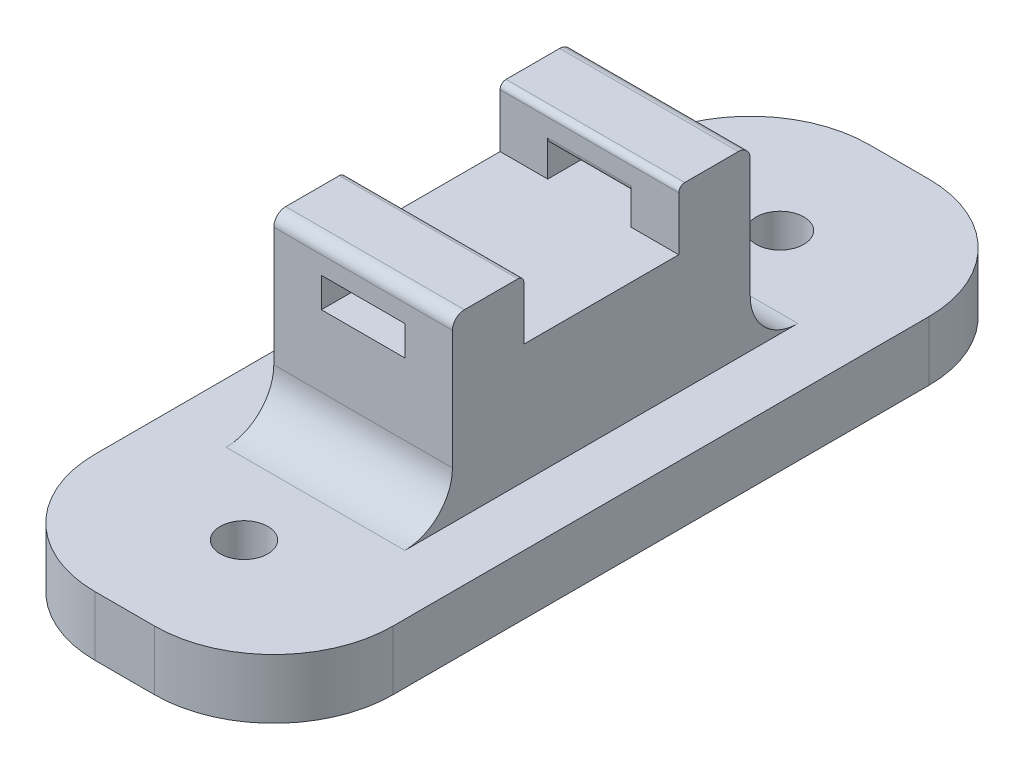
from build123d import *

# Parameters (mm, degrees)
SKETCH1_W           = 25
SKETCH1_H           = 65
BOSS_EXTRUDE1_DEPTH = 5
SKETCH2_R           = 2
CUT_EXTRUDE1_DEPTH  = 6
SKETCH3_W           = 15
SKETCH3_H           = 25
BOSS_EXTRUDE2_DEPTH = 10
SKETCH4_W           = 15
SKETCH4_H           = 6
BOSS_EXTRUDE3_DEPTH = 5
SKETCH5_W           = 7
SKETCH5_H           = 2.5
CUT_EXTRUDE2_DEPTH  = 46
FILLET1_R           = 0.5
FILLET2_R           = 0.5
FILLET3_R           = 1
FILLET4_R           = 10
FILLET5_R           = 4


with BuildPart() as part:
    # Sketch1 → Boss-Extrude1 (new body)
    with BuildSketch(Plane(origin=(0, 0, 0), x_dir=(1, 0, 0), z_dir=(0, 1, 0))):
        with Locations((12.5, 32.5)):
            Rectangle(SKETCH1_W, SKETCH1_H)
    extrude(amount=BOSS_EXTRUDE1_DEPTH)

    # Sketch2 → Cut-Extrude1 (cut, through all)
    with BuildSketch(Plane(origin=(0, 0, 0), x_dir=(1, 0, 0), z_dir=(0, 1, 0))):
        with Locations((12.5, 55)):
            Circle(SKETCH2_R)
        with Locations((12.5, 10)):
            Circle(SKETCH2_R)
    extrude(amount=CUT_EXTRUDE1_DEPTH, mode=Mode.SUBTRACT)

    # Sketch3 → Boss-Extrude2 (add)
    with BuildSketch(Plane(origin=(0, 5, 0), x_dir=(1, 0, 0), z_dir=(0, 1, 0))):
        with Locations((12.5, 32.5)):
            Rectangle(SKETCH3_W, SKETCH3_H)
    extrude(amount=BOSS_EXTRUDE2_DEPTH)

    # Sketch4 → Boss-Extrude3 (add)
    with BuildSketch(Plane(origin=(0, 15, 0), x_dir=(1, 0, 0), z_dir=(0, 1, 0))):
        with Locations((12.5, 42)):
            Rectangle(SKETCH4_W, SKETCH4_H)
        with Locations((12.5, 23)):
            Rectangle(SKETCH4_W, SKETCH4_H)
    extrude(amount=BOSS_EXTRUDE3_DEPTH)

    # Sketch5 → Cut-Extrude2 (cut, through all)
    with BuildSketch(Plane(origin=(0, 0, -45), x_dir=(-1, 0, 0), z_dir=(0, 0, -1))):
        with Locations((-12.5, 16.25)):
            Rectangle(SKETCH5_W, SKETCH5_H)
    extrude(amount=-CUT_EXTRUDE2_DEPTH, mode=Mode.SUBTRACT)

    # Fillet1
    fillet1_edges = [part.edges().sort_by_distance(p)[0] for p in [
        (12.5, 20, -39),
        (12.5, 17.5, -39),
    ]]
    fillet(fillet1_edges, radius=FILLET1_R)

    # Fillet2
    fillet2_edges = [part.edges().sort_by_distance(p)[0] for p in [
        (12.5, 20, -26),
        (12.5, 17.5, -26),
    ]]
    fillet(fillet2_edges, radius=FILLET2_R)

    # Fillet3
    fillet3_edges = [part.edges().sort_by_distance(p)[0] for p in [
        (12.5, 20, -45),
        (12.5, 20, -20),
    ]]
    fillet(fillet3_edges, radius=FILLET3_R)

    # Fillet4
    fillet4_edges = [part.edges().sort_by_distance(p)[0] for p in [
        (0, 2.5, -65),
        (25, 2.5, -65),
        (25, 2.5, 0),
        (0, 2.5, 0),
    ]]
    fillet(fillet4_edges, radius=FILLET4_R)

    # Fillet5
    fillet5_edges = [part.edges().sort_by_distance(p)[0] for p in [
        (12.5, 5, -45),
        (12.5, 5, -20),
    ]]
    fillet(fillet5_edges, radius=FILLET5_R)


solid = part.part
